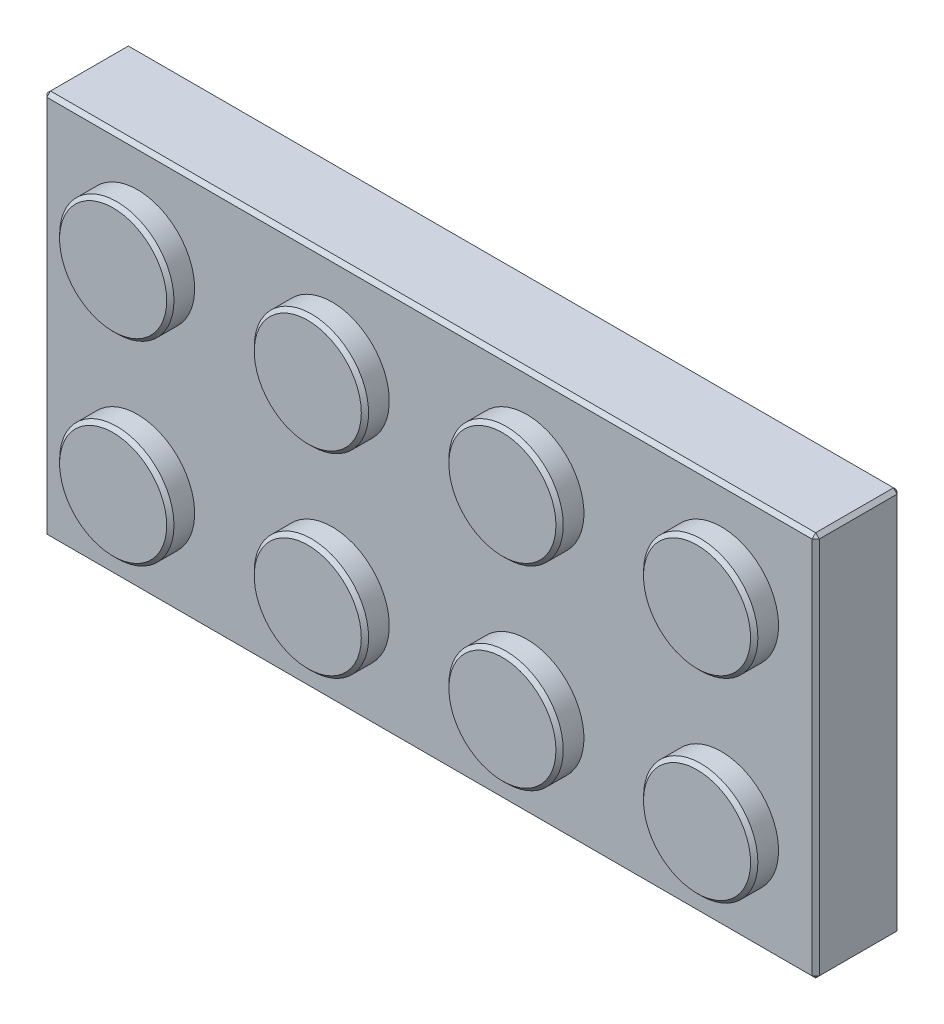
from build123d import *

# Parameters (mm, degrees)
SKIZZE1_W                       = 63.5
SKIZZE1_H                       = 31.7
AUFSATZ_LINEAR_AUSTRAGEN1_DEPTH = 7
SKIZZE2_R                       = 4.7
AUFSATZ_LINEAR_AUSTRAGEN2_DEPTH = 2
LINEARES_MUSTER3_COUNT          = 4
LINEARES_MUSTER3_PITCH          = 16
LINEARES_MUSTER3_COUNT_DIR2     = 2
LINEARES_MUSTER3_PITCH_DIR2     = 16
SCHNITT_LINEAR_AUSTRAGEN2_DEPTH = 2.5
AUFSATZ_LINEAR_AUSTRAGEN3_DEPTH = 2.5
LINEARES_MUSTER6_COUNT          = 3
LINEARES_MUSTER6_PITCH          = 16
FASE1_SIZE                      = 0.3
FASE2_SIZE                      = 0.3


with BuildPart() as part:
    # Skizze1 → Aufsatz-Linear austragen1 (new body)
    with BuildSketch(Plane.XY):
        Rectangle(SKIZZE1_W, SKIZZE1_H)
    extrude(amount=AUFSATZ_LINEAR_AUSTRAGEN1_DEPTH)

    # Skizze2 → Aufsatz-Linear austragen2 (add)
    with BuildSketch(Plane.XY.offset(7)):
        with Locations(Location((-24, 8, 0), (0, 0, 180))):  # turned: the seam where the file's is
            Circle(SKIZZE2_R)
    aufsatz_linear_austragen2 = extrude(amount=AUFSATZ_LINEAR_AUSTRAGEN2_DEPTH)

    # Lineares Muster3: Aufsatz-Linear austragen2 4 × 2
    with Locations(*[(i * LINEARES_MUSTER3_PITCH, -j * LINEARES_MUSTER3_PITCH_DIR2, 0) for i in range(LINEARES_MUSTER3_COUNT) for j in range(LINEARES_MUSTER3_COUNT_DIR2) if (i, j) != (0, 0)]):
        add(aufsatz_linear_austragen2)

    # Skizze8 → Schnitt-Linear austragen2 (cut)
    with BuildSketch(Plane(origin=(0, 0, 0), x_dir=(-1, 0, 0), z_dir=(0, 0, -1))):
        with BuildLine():
            ThreePointArc((-25.047729273, -12.633008026), (-24.205299127, -12.745561323), (-23.356296162, -12.706181612))
            ThreePointArc((-23.356296162, -12.706181612), (-16, -15.1), (-8.643703838, -12.706181612))
            ThreePointArc((-8.643703838, -12.706181612), (-8, -12.75), (-7.356296162, -12.706181612))
            ThreePointArc((-7.356296162, -12.706181612), (0, -15.1), (7.356296162, -12.706181612))
            ThreePointArc((7.356296162, -12.706181612), (8, -12.75), (8.643703838, -12.706181612))
            ThreePointArc((8.643703838, -12.706181612), (16, -15.1), (23.356296162, -12.706181612))
            ThreePointArc((23.356296162, -12.706181612), (24.205299127, -12.745561323), (25.047729273, -12.633008026))
            ThreePointArc((25.047729273, -12.633008026), (30.094971556, -14.247345845), (28.605730038, -9.161787768))
            ThreePointArc((28.605730038, -9.161787768), (28.745542641, -8.205730515), (28.688993778, -7.241160527))
            ThreePointArc((28.688993778, -7.241160527), (31, 0), (28.688993778, 7.241160527))
            ThreePointArc((28.688993778, 7.241160527), (28.745542641, 8.205730515), (28.605730038, 9.161787768))
            ThreePointArc((28.605730038, 9.161787768), (30.094971556, 14.247345845), (25.047729273, 12.633008026))
            ThreePointArc((25.047729273, 12.633008026), (24.205299127, 12.745561323), (23.356296162, 12.706181612))
            ThreePointArc((23.356296162, 12.706181612), (16, 15.1), (8.643703838, 12.706181612))
            ThreePointArc((8.643703838, 12.706181612), (8, 12.75), (7.356296162, 12.706181612))
            ThreePointArc((7.356296162, 12.706181612), (0, 15.1), (-7.356296162, 12.706181612))
            ThreePointArc((-7.356296162, 12.706181612), (-8, 12.75), (-8.643703838, 12.706181612))
            ThreePointArc((-8.643703838, 12.706181612), (-16, 15.1), (-23.356296162, 12.706181612))
            ThreePointArc((-23.356296162, 12.706181612), (-24.205299127, 12.745561323), (-25.047729273, 12.633008026))
            ThreePointArc((-25.047729273, 12.633008026), (-30.094971556, 14.247345845), (-28.605730038, 9.161787768))
            ThreePointArc((-28.605730038, 9.161787768), (-28.745542641, 8.205730515), (-28.688993778, 7.241160527))
            ThreePointArc((-28.688993778, 7.241160527), (-31, 0), (-28.688993778, -7.241160527))
            ThreePointArc((-28.688993778, -7.241160527), (-28.745542641, -8.205730515), (-28.605730038, -9.161787768))
            ThreePointArc((-28.605730038, -9.161787768), (-30.094971556, -14.247345845), (-25.047729273, -12.633008026))
        make_face()
    extrude(amount=-SCHNITT_LINEAR_AUSTRAGEN2_DEPTH, mode=Mode.SUBTRACT)

    # Skizze9 → Aufsatz-Linear austragen3 (add)
    with BuildSketch(Plane(origin=(0, 0, 2.5), x_dir=(-1, 0, 0), z_dir=(0, 0, -1))):
        with BuildLine():
            Line((-11.990588165, -5.423625397), (-13.171572875, -4.242640687))
            ThreePointArc((-13.171572875, -4.242640687), (-16, -3.071067812), (-18.828427125, -4.242640687))
            Line((-18.828427125, -4.242640687), (-20.009411835, -5.423625397))
            ThreePointArc((-20.009411835, -5.423625397), (-20.641242789, -4.641242789), (-21.423625397, -4.009411835))
            Line((-21.423625397, -4.009411835), (-20.242640687, -2.828427125))
            ThreePointArc((-20.242640687, -2.828427125), (-19.071067812, 0), (-20.242640687, 2.828427125))
            Line((-20.242640687, 2.828427125), (-21.423625397, 4.009411835))
            ThreePointArc((-21.423625397, 4.009411835), (-20.641242789, 4.641242789), (-20.009411835, 5.423625397))
            Line((-20.009411835, 5.423625397), (-18.828427125, 4.242640687))
            ThreePointArc((-18.828427125, 4.242640687), (-16, 3.071067812), (-13.171572875, 4.242640687))
            Line((-13.171572875, 4.242640687), (-11.990588165, 5.423625397))
            ThreePointArc((-11.990588165, 5.423625397), (-11.358757211, 4.641242789), (-10.576374603, 4.009411835))
            Line((-10.576374603, 4.009411835), (-11.757359313, 2.828427125))
            ThreePointArc((-11.757359313, 2.828427125), (-12.928932188, 0), (-11.757359313, -2.828427125))
            Line((-11.757359313, -2.828427125), (-10.576374603, -4.009411835))
            ThreePointArc((-10.576374603, -4.009411835), (-11.358757211, -4.641242789), (-11.990588165, -5.423625397))
        make_face()
    aufsatz_linear_austragen3 = extrude(amount=AUFSATZ_LINEAR_AUSTRAGEN3_DEPTH)

    # Lineares Muster6: Aufsatz-Linear austragen3 ×3
    with Locations(*[(-i * LINEARES_MUSTER6_PITCH, 0, 0) for i in range(1, LINEARES_MUSTER6_COUNT)]):
        add(aufsatz_linear_austragen3)

    # Fase1
    fase1_edges = [part.edges().sort_by_distance(p)[0] for p in [
        (31.75, 0, 7),
        (0, 15.85, 7),
        (-19.3, 8, 9),
        (-3.3, 8, 9),
        (12.7, 8, 9),
        (28.7, 8, 9),
        (-19.3, -8, 9),
        (-3.3, -8, 9),
        (12.7, -8, 9),
        (28.7, -8, 9),
        (-31.75, 0, 7),
        (0, -15.85, 7),
        (-31.75, 15.85, 3.5),
        (31.75, 15.85, 3.5),
        (31.75, -15.85, 3.5),
        (-31.75, -15.85, 3.5),
    ]]
    chamfer(fase1_edges, length=FASE1_SIZE)

    # Fase2
    fase2_edges = [part.edges().sort_by_distance(p)[0] for p in [
        (20.641242789, -4.641242789, 0),
        (16, -3.071067812, 0),
        (12.58108052, -4.833133042, 0),
        (11.358757211, -4.641242789, 0),
        (11.166866958, -3.41891948, 0),
        (11.358757211, 4.641242789, 0),
        (12.58108052, 4.833133042, 0),
        (16, 3.071067812, 0),
        (19.41891948, 4.833133042, 0),
        (20.641242789, 4.641242789, 0),
        (20.833133042, -3.41891948, 0),
        (19.41891948, -4.833133042, 0),
        (12.928932188, 0, 0),
        (11.166866958, 3.41891948, 0),
        (20.833133042, 3.41891948, 0),
        (19.071067812, 0, 0),
        (4.641242789, -4.641242789, 0),
        (0, -3.071067812, 0),
        (-3.41891948, -4.833133042, 0),
        (-4.641242789, -4.641242789, 0),
        (-4.833133042, -3.41891948, 0),
        (-4.641242789, 4.641242789, 0),
        (-3.41891948, 4.833133042, 0),
        (0, 3.071067812, 0),
        (3.41891948, 4.833133042, 0),
        (4.641242789, 4.641242789, 0),
        (4.833133042, -3.41891948, 0),
        (3.41891948, -4.833133042, 0),
        (-3.071067812, 0, 0),
        (-4.833133042, 3.41891948, 0),
        (4.833133042, 3.41891948, 0),
        (3.071067812, 0, 0),
        (-11.358757211, -4.641242789, 0),
        (-16, -3.071067812, 0),
        (-19.41891948, -4.833133042, 0),
        (-20.641242789, -4.641242789, 0),
        (-20.833133042, -3.41891948, 0),
        (-20.641242789, 4.641242789, 0),
        (-19.41891948, 4.833133042, 0),
        (-16, 3.071067812, 0),
        (-12.58108052, 4.833133042, 0),
        (-11.358757211, 4.641242789, 0),
        (-11.166866958, -3.41891948, 0),
        (-12.58108052, -4.833133042, 0),
        (-19.071067812, 0, 0),
        (-20.833133042, 3.41891948, 0),
        (-11.166866958, 3.41891948, 0),
        (-12.928932188, 0, 0),
        (31.75, 0, 0),
        (-31.75, 0, 0),
        (0, 15.85, 0),
        (0, -15.85, 0),
        (-31.6, 15.7, 0),
        (31.6, 15.7, 0),
        (-31.6, -15.7, 0),
        (31.6, -15.7, 0),
        (-24.205299127, -12.745561323, 0),
        (-16, -15.1, 0),
        (-8, -12.75, 0),
        (30.094971556, -14.247345845, 0),
        (30.094971556, 14.247345845, 0),
        (16, 15.1, 0),
        (0, 15.1, 0),
        (-8, 12.75, 0),
        (-24.205299127, 12.745561323, 0),
        (-28.745542641, 8.205730515, 0),
        (-31, 0, 0),
        (-28.745542641, -8.205730515, 0),
        (-30.094971556, -14.247345845, 0),
        (-30.094971556, 14.247345845, 0),
        (-16, 15.1, 0),
        (8, 12.75, 0),
        (24.205299127, 12.745561323, 0),
        (28.745542641, 8.205730515, 0),
        (31, 0, 0),
        (28.745542641, -8.205730515, 0),
        (24.205299127, -12.745561323, 0),
        (16, -15.1, 0),
        (8, -12.75, 0),
        (0, -15.1, 0),
    ]]
    chamfer(fase2_edges, length=FASE2_SIZE)


solid = part.part
